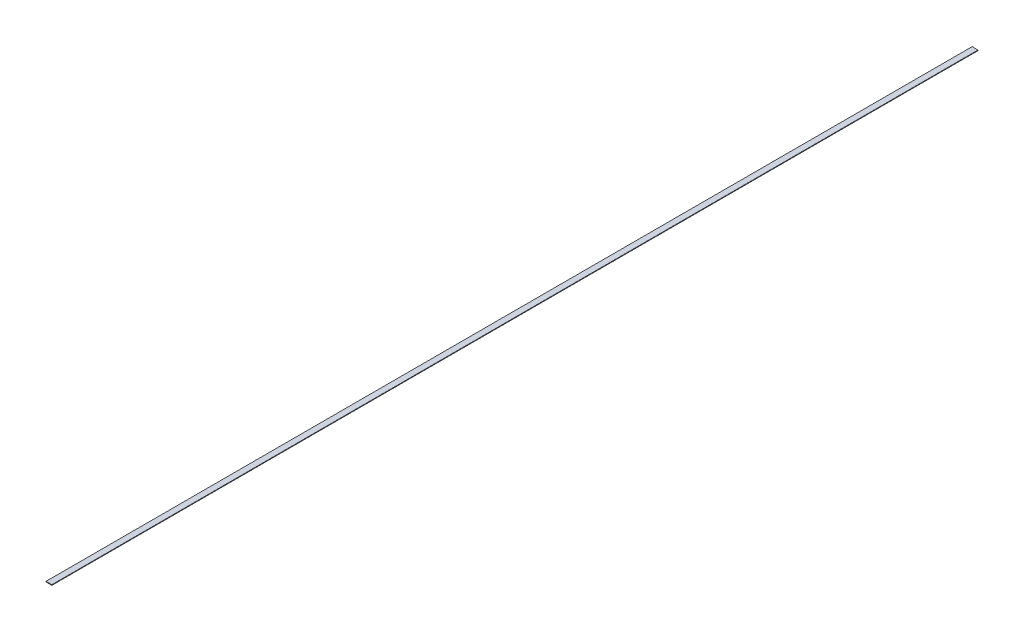
from build123d import *

# Parameters (mm, degrees)
SKETCH1_W           = 50.8
SKETCH1_H           = 8051.8
BOSS_EXTRUDE1_DEPTH = 5.08


with BuildPart() as part:
    # Sketch1 → Boss-Extrude1 (new body)
    with BuildSketch(Plane(origin=(0, 0, 0), x_dir=(1, 0, 0), z_dir=(0, 1, 0))):
        with Locations((25.4, 4025.9)):
            Rectangle(SKETCH1_W, SKETCH1_H)
    extrude(amount=BOSS_EXTRUDE1_DEPTH)


solid = part.part
